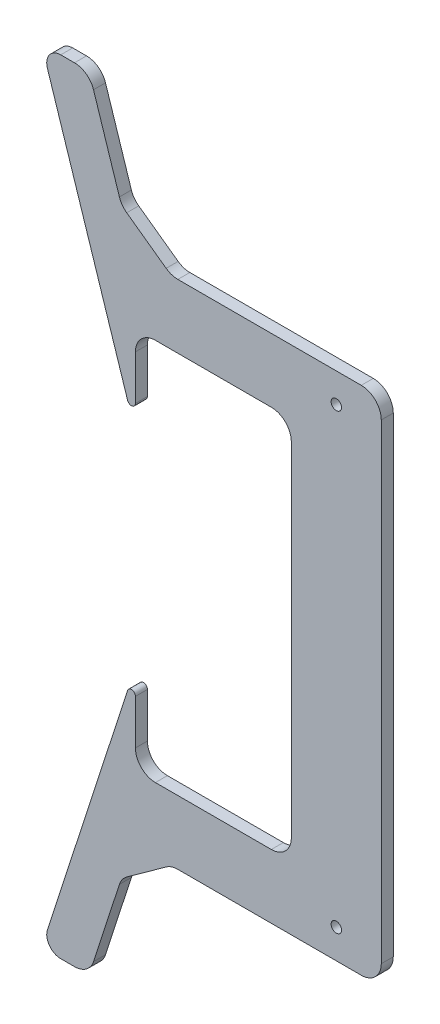
from build123d import *

# Parameters (mm, degrees)
ESBO_O1_R                = 2.6
RESSALTO_EXTRUS_O1_DEPTH = 6
FILETE1_R                = 2
FILETE3_R                = 10
FILETE4_R                = 7


with BuildPart() as part:
    # Esboço1 → Ressalto-extrusão1 (new body)
    with BuildSketch(Plane.XY):
        Polygon((-100.5, 95.8), (-22.5, 95.8), (-22.5, -95.8), (-100.5, -95.8), (-100.5, -50.8), (-147.5, -195.8), (-123.706896552, -195.8), (-107.5, -145.8), (-82.5, -127.8), (22.5, -127.8), (22.5, 127.8), (-82.5, 127.8), (-107.5, 145.8), (-123.706896552, 195.8), (-147.5, 195.8), (-100.5, 50.8), align=None)
        with Locations((0, 113.2)):
            Circle(ESBO_O1_R, mode=Mode.SUBTRACT)
        with Locations((0, -113.2)):
            Circle(ESBO_O1_R, mode=Mode.SUBTRACT)
    extrude(amount=RESSALTO_EXTRUS_O1_DEPTH)

    # Filete1
    filete1_edges = [part.edges().sort_by_distance(p)[0] for p in [
        (-100.5, -50.8, 3),
        (-100.5, 50.8, 3),
    ]]
    fillet(filete1_edges, radius=FILETE1_R)

    # Filete3
    filete3_edges = [part.edges().sort_by_distance(p)[0] for p in [
        (-82.5, 127.8, 3),
        (22.5, 127.8, 3),
        (22.5, -127.8, 3),
        (-82.5, -127.8, 3),
        (-107.5, -145.8, 3),
        (-123.706896552, -195.8, 3),
        (-100.5, -95.8, 3),
        (-22.5, -95.8, 3),
        (-22.5, 95.8, 3),
        (-100.5, 95.8, 3),
        (-123.706896552, 195.8, 3),
        (-107.5, 145.8, 3),
    ]]
    fillet(filete3_edges, radius=FILETE3_R)

    # Filete4
    filete4_edges = [part.edges().sort_by_distance(p)[0] for p in [
        (-147.5, -195.8, 3),
        (-147.5, 195.8, 3),
    ]]
    fillet(filete4_edges, radius=FILETE4_R)


solid = part.part
